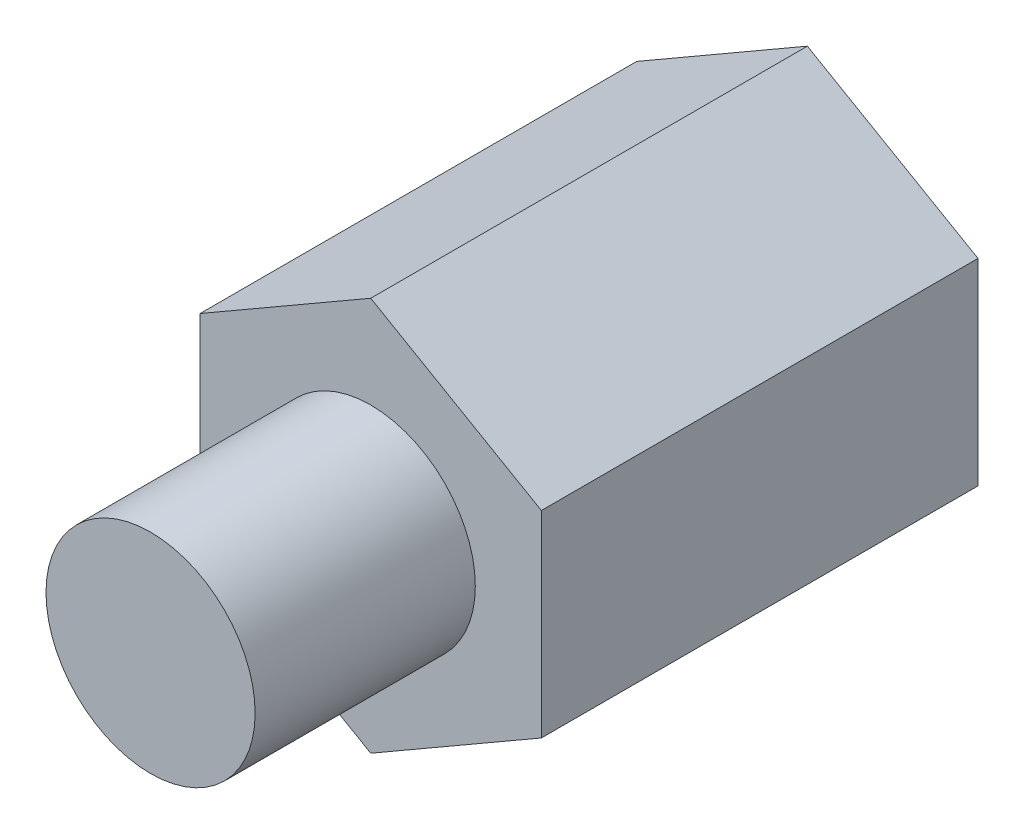
from build123d import *

# Parameters (mm, degrees)
CROQUIS1_R              = 1.2
SALIENTE_EXTRUIR1_DEPTH = 5.95
CROQUIS2_R              = 1.425
SALIENTE_EXTRUIR2_DEPTH = 3


with BuildPart() as part:
    # Croquis1 → Saliente-Extruir1 (new body)
    with BuildSketch(Plane.XY):
        Polygon((0, -2.684678752), (2.325, -1.342339376), (2.325, 1.342339376), (0, 2.684678752), (-2.325, 1.342339376), (-2.325, -1.342339376), align=None)
        Circle(CROQUIS1_R, mode=Mode.SUBTRACT)
    extrude(amount=SALIENTE_EXTRUIR1_DEPTH)

    # Croquis2 → Saliente-Extruir2 (add)
    with BuildSketch(Plane.XY.offset(5.95)):
        Circle(CROQUIS2_R)
    extrude(amount=SALIENTE_EXTRUIR2_DEPTH)


solid = part.part
